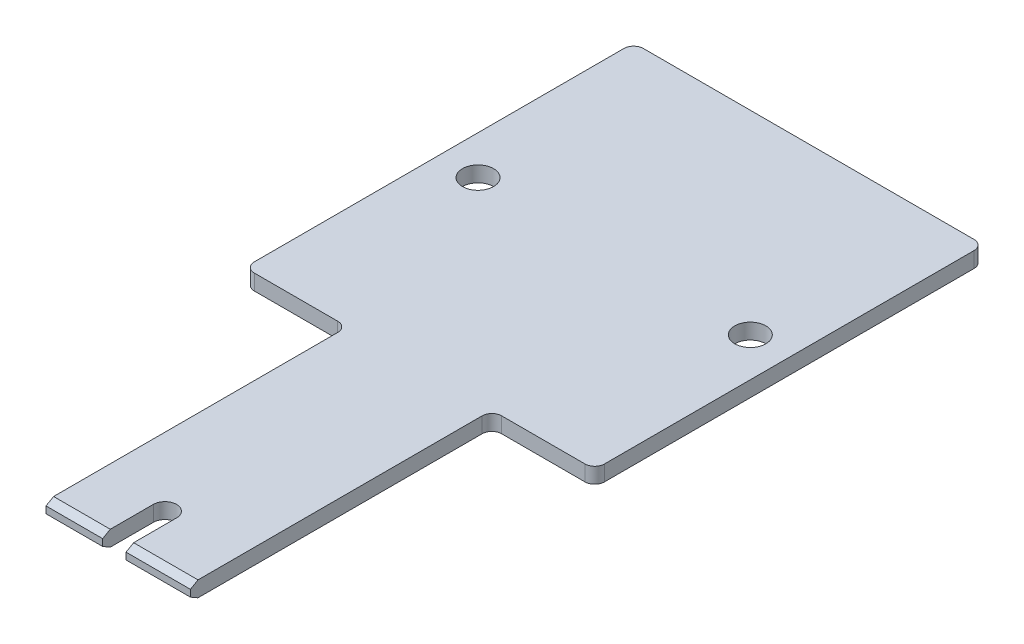
from build123d import *

# Parameters (mm, degrees)
BOSS_EXTRUDE1_DEPTH            = 1.6
CHAMFER1_SIZE                  = 0.45
CHAMFER1_SIZE2                 = 0.779422863
FILLET1_R                      = 1
CUT_EXTRUDE1_DEPTH             = 2.6
F_3_2_3_2_DIAMETER_HOLE1_D     = 3.2
F_3_2_3_2_DIAMETER_HOLE1_DEPTH = 1.6
F_3_2_3_2_DIAMETER_HOLE1_TIP   = 0.96137699


with BuildPart() as part:
    # Sketch1 → Boss-Extrude1 (new body)
    with BuildSketch(Plane(origin=(0, 0, 0), x_dir=(1, 0, 0), z_dir=(0, 1, 0))):
        Polygon((-7.425, 15.5), (-18, 15.5), (-18, 55.5), (18, 55.5), (18, 15.5), (7.425, 15.5), (7.425, -15.5), (-7.425, -15.5), align=None)
    extrude(amount=BOSS_EXTRUDE1_DEPTH)

    # Chamfer1
    chamfer1_edges = [part.edges().sort_by_distance(p)[0] for p in [
        (0, 1.6, 15.5),
        (0, 0, 15.5),
    ]]
    chamfer1_side = [part.faces().sort_by_distance(p)[0] for p in [
        (0, 0.8, 15.5),
    ]]
    chamfer(chamfer1_edges, length=CHAMFER1_SIZE, length2=CHAMFER1_SIZE2, reference=chamfer1_side[0])

    # Fillet1
    fillet1_edges = [part.edges().sort_by_distance(p)[0] for p in [
        (-7.425, 0.8, -15.5),
        (-18, 0.8, -15.5),
        (-18, 0.8, -55.5),
        (18, 0.8, -55.5),
        (18, 0.8, -15.5),
        (7.425, 0.8, -15.5),
    ]]
    fillet(fillet1_edges, radius=FILLET1_R)

    # Sketch2 → Cut-Extrude1 (cut, through all)
    with BuildSketch(Plane(origin=(0, 1.6, 0), x_dir=(1, 0, 0), z_dir=(0, 1, 0))):
        with BuildLine():
            Line((-1.595, -10.3), (-1.595, -15.5))
            Line((-1.595, -15.5), (0.805, -15.5))
            Line((0.805, -15.5), (0.805, -10.3))
            ThreePointArc((0.805, -10.3), (-0.395, -9.1), (-1.595, -10.3))
        make_face()
    extrude(amount=-CUT_EXTRUDE1_DEPTH, mode=Mode.SUBTRACT)

    # Ø3.2 (3.2) Diameter Hole1
    with Locations(Plane(origin=(-14, 1.6, -35.5), x_dir=(0, 0, 1), z_dir=(0, 1, 0))):
        with Locations((0, 0), (0, 28)):
            Hole(F_3_2_3_2_DIAMETER_HOLE1_D / 2, depth=F_3_2_3_2_DIAMETER_HOLE1_DEPTH)
            with Locations((0, 0, -(F_3_2_3_2_DIAMETER_HOLE1_DEPTH + F_3_2_3_2_DIAMETER_HOLE1_TIP / 2))):  # 118° drill point
                Cone(0, F_3_2_3_2_DIAMETER_HOLE1_D / 2, F_3_2_3_2_DIAMETER_HOLE1_TIP, mode=Mode.SUBTRACT)


solid = part.part
